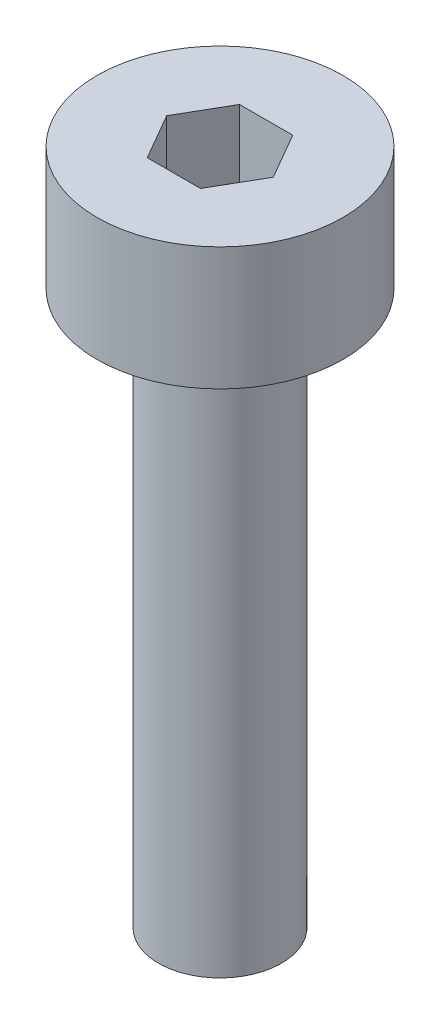
from build123d import *

# Parameters (mm, degrees)
SKETCH_1_R            = 2
EXTRUDE_246_DEPTH     = 2
CUT_EXTRUDE_376_DEPTH = 1.5
SKETCH_3_R            = 1
EXTRUDE_477_DEPTH     = 9


with BuildPart() as part:
    # 草图1 → Extrude 246 (new body)
    with BuildSketch(Plane(origin=(0, 0, 0), x_dir=(1, 0, 0), z_dir=(0, 1, 0))):
        Circle(SKETCH_1_R)
    extrude(amount=EXTRUDE_246_DEPTH)

    # 草图2 → Cut-Extrude 376 (cut)
    with BuildSketch(Plane(origin=(0, 2, 0), x_dir=(1, 0, 0), z_dir=(0, 1, 0))):
        Polygon((0.866025404, 0), (0.433012702, 0.75), (-0.433012702, 0.75), (-0.866025404, 0), (-0.433012702, -0.75), (0.433012702, -0.75), align=None)
    extrude(amount=-CUT_EXTRUDE_376_DEPTH, mode=Mode.SUBTRACT)

    # 草图3 → Extrude 477 (add)
    with BuildSketch(Plane.XZ):
        Circle(SKETCH_3_R)
    extrude(amount=EXTRUDE_477_DEPTH)


solid = part.part
